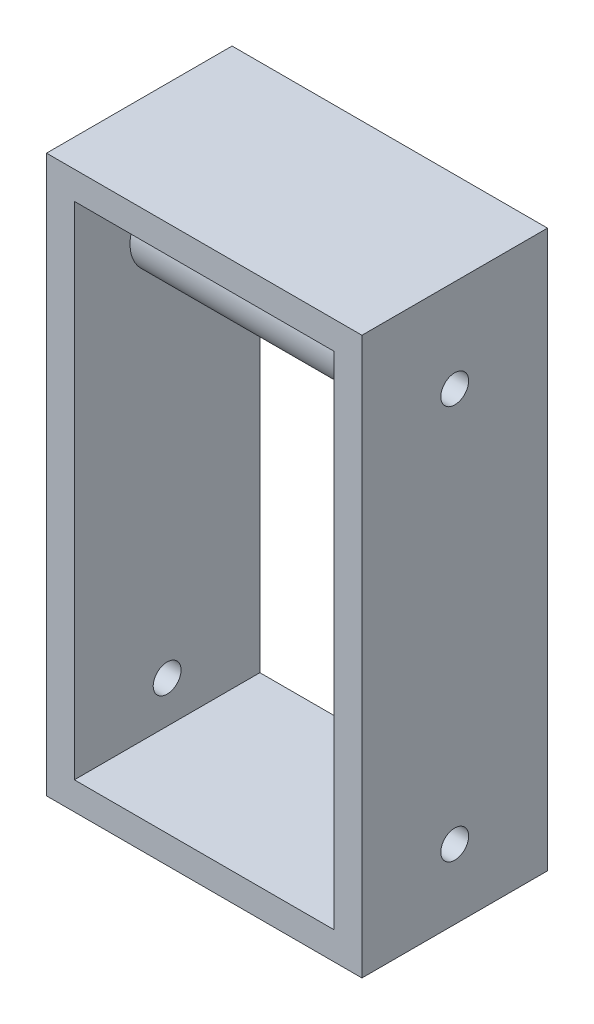
from build123d import *

# Parameters (mm, degrees)
SKETCH1_W               = 34
SKETCH1_H               = 60
SKETCH1_W_2             = 28
SKETCH1_H_2             = 54
BOSS_EXTRUDE1_DEPTH     = 20
SKETCH2_R               = 1.5
CUT_EXTRUDE1_DEPTH      = 1
CUT_EXTRUDE1_DEPTH_BACK = 35
SKETCH4_R               = 4
BOSS_EXTRUDE2_DEPTH     = 28


with BuildPart() as part:
    # Sketch1 → Boss-Extrude1 (new body)
    with BuildSketch(Plane.XY):
        Rectangle(SKETCH1_W, SKETCH1_H)
        Rectangle(SKETCH1_W_2, SKETCH1_H_2, mode=Mode.SUBTRACT)
    extrude(amount=BOSS_EXTRUDE1_DEPTH)

    # Sketch2 → Cut-Extrude1 (cut, two sides)
    with BuildSketch(Plane(origin=(17, 0, 0), x_dir=(0, 0, -1), z_dir=(1, 0, 0))) as cut_extrude1_sk:
        with Locations((-10, -22.5)):
            Circle(SKETCH2_R)
        with Locations((-10, 20)):
            Circle(SKETCH2_R)
    extrude(amount=CUT_EXTRUDE1_DEPTH, mode=Mode.SUBTRACT)
    extrude(cut_extrude1_sk.sketch, amount=-CUT_EXTRUDE1_DEPTH_BACK, mode=Mode.SUBTRACT)

    # Sketch4 → Boss-Extrude2 (add)
    with BuildSketch(Plane.ZY.offset(-14)):
        with Locations((10, 20)):
            Circle(SKETCH4_R)
    extrude(amount=BOSS_EXTRUDE2_DEPTH)


solid = part.part
